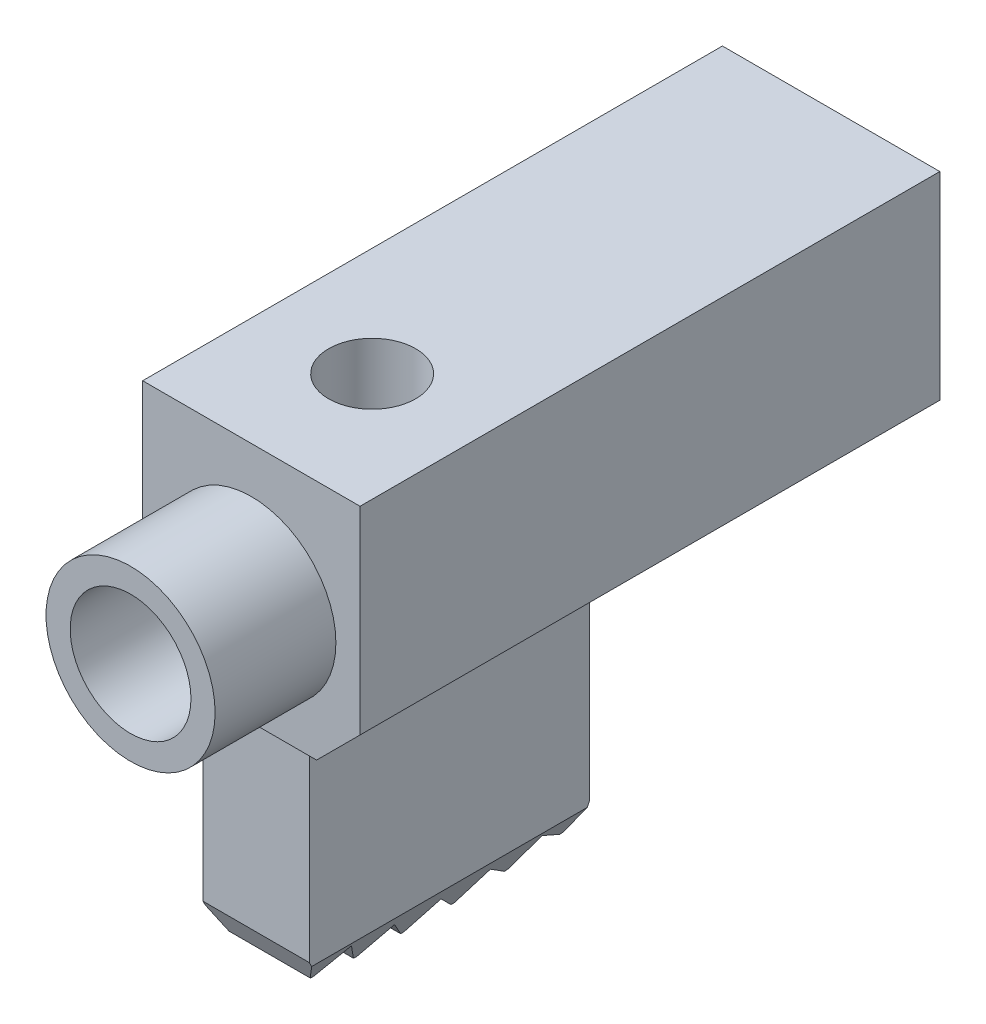
from build123d import *

# Parameters (mm, degrees)
SKETCH1_W                      = 4.5
SKETCH1_H                      = 5
BOSS_EXTRUDE1_DEPTH            = 12
SKETCH4_R                      = 1.75
BOSS_EXTRUDE3_DEPTH            = 2.5
SKETCH5_R                      = 1.25
CUT_EXTRUDE1_DEPTH             = 15.5
SKETCH7_W                      = 2.2
SKETCH7_H                      = 4.7
BOSS_EXTRUDE4_DEPTH            = 5.8
CUT_EXTRUDE2_DEPTH             = 13
CUT_EXTRUDE6_DEPTH             = 12.9
CUT_EXTRUDE3_DEPTH             = 3.25
CUT_EXTRUDE3_DEPTH_BACK        = 3.25
CUT_EXTRUDE4_DEPTH             = 3.25
CIRPATTERN3_COUNT              = 60
F_1_8_1_8_DIAMETER_HOLE1_D     = 1.8
F_1_8_1_8_DIAMETER_HOLE1_DEPTH = 8.2
F_1_8_1_8_DIAMETER_HOLE1_TIP   = 0.540774557


with BuildPart() as part:
    # Sketch1 → Boss-Extrude1 (new body)
    with BuildSketch(Plane.XY):
        with Locations((0, 0.2)):
            Rectangle(SKETCH1_W, SKETCH1_H)
    extrude(amount=BOSS_EXTRUDE1_DEPTH)

    # Sketch4 → Boss-Extrude3 (add)
    with BuildSketch(Plane.XY.offset(12)):
        Circle(SKETCH4_R)
    extrude(amount=BOSS_EXTRUDE3_DEPTH)

    # Sketch5 → Cut-Extrude1 (cut, through all)
    with BuildSketch(Plane.XY.offset(14.5)):
        Circle(SKETCH5_R)
    extrude(amount=-CUT_EXTRUDE1_DEPTH, mode=Mode.SUBTRACT)

    # Sketch7 → Boss-Extrude4 (add)
    with BuildSketch(Plane.XY.offset(6.1)):
        with Locations((0, -4.65)):
            Rectangle(SKETCH7_W, SKETCH7_H)
    extrude(amount=BOSS_EXTRUDE4_DEPTH)

    # Sketch8 → Cut-Extrude2 (cut, through all)
    with BuildSketch(Plane.XY.offset(12)):
        Polygon((1.35, -2.3), (2.25, -1.4), (2.25, -2.3), align=None)
        Polygon((-1.35, -2.3), (-2.25, -2.3), (-2.25, -1.4), align=None)
    extrude(amount=-CUT_EXTRUDE2_DEPTH, mode=Mode.SUBTRACT)

    # Sketch10 → Cut-Extrude6 (cut, through all)
    with BuildSketch(Plane.XY.offset(11.9)):
        Polygon((-0.638119785, -7), (-1.1, -7), (-1.1, -6.2), align=None)
        Polygon((1.1, -7), (1.1, -6.2), (0.638119785, -7), align=None)
    extrude(amount=-CUT_EXTRUDE6_DEPTH, mode=Mode.SUBTRACT)

    # Sketch9 → Cut-Extrude3 (cut, two sides)
    with BuildSketch(Plane(origin=(0, 0, 0), x_dir=(0, 0, -1), z_dir=(1, 0, 0))) as cut_extrude3_sk:
        with BuildLine():
            Line((-11.9, -6.570266454), (-11.9, -8))
            Line((-11.9, -8), (-6.1, -8))
            Line((-6.1, -8), (-6.1, -6.570266454))
            ThreePointArc((-6.1, -6.570266454), (-9, -7), (-11.9, -6.570266454))
        make_face()
    extrude(amount=CUT_EXTRUDE3_DEPTH, mode=Mode.SUBTRACT)
    extrude(cut_extrude3_sk.sketch, amount=-CUT_EXTRUDE3_DEPTH_BACK, mode=Mode.SUBTRACT)

    # Sketch9_3 → Cut-Extrude4 (cut, symmetric)
    with BuildSketch(Plane(origin=(0, 0, 0), x_dir=(0, 0, -1), z_dir=(1, 0, 0))):
        with BuildLine():
            Line((-8.51191829, -6.98808171), (-9, -6.5))
            Line((-9, -6.5), (-9.48808171, -6.98808171))
            ThreePointArc((-9.48808171, -6.98808171), (-9, -7), (-8.51191829, -6.98808171))
        make_face()
    cut_extrude4 = extrude(amount=CUT_EXTRUDE4_DEPTH, both=True, mode=Mode.SUBTRACT)

    # CirPattern3: Cut-Extrude4 ×60 about axis, 6 skipped
    cirpattern3_axis = Axis((0, 3, 9), (1, 0, 0))
    add([cut_extrude4.rotate(cirpattern3_axis, i * 360 / CIRPATTERN3_COUNT) for i in range(1, CIRPATTERN3_COUNT) if i not in (8, 9, 10, 11, 12, 13)], mode=Mode.SUBTRACT)

    # Ø1.8 (1.8) Diameter Hole1
    with Locations(Plane(origin=(0, 2.7, 0), x_dir=(1, 0, 0), z_dir=(0, 1, 0))):
        with Locations((0, -9.5)):
            Hole(F_1_8_1_8_DIAMETER_HOLE1_D / 2, depth=F_1_8_1_8_DIAMETER_HOLE1_DEPTH)
            with Locations((0, 0, -(F_1_8_1_8_DIAMETER_HOLE1_DEPTH + F_1_8_1_8_DIAMETER_HOLE1_TIP / 2))):  # 118° drill point
                Cone(0, F_1_8_1_8_DIAMETER_HOLE1_D / 2, F_1_8_1_8_DIAMETER_HOLE1_TIP, mode=Mode.SUBTRACT)


solid = part.part
